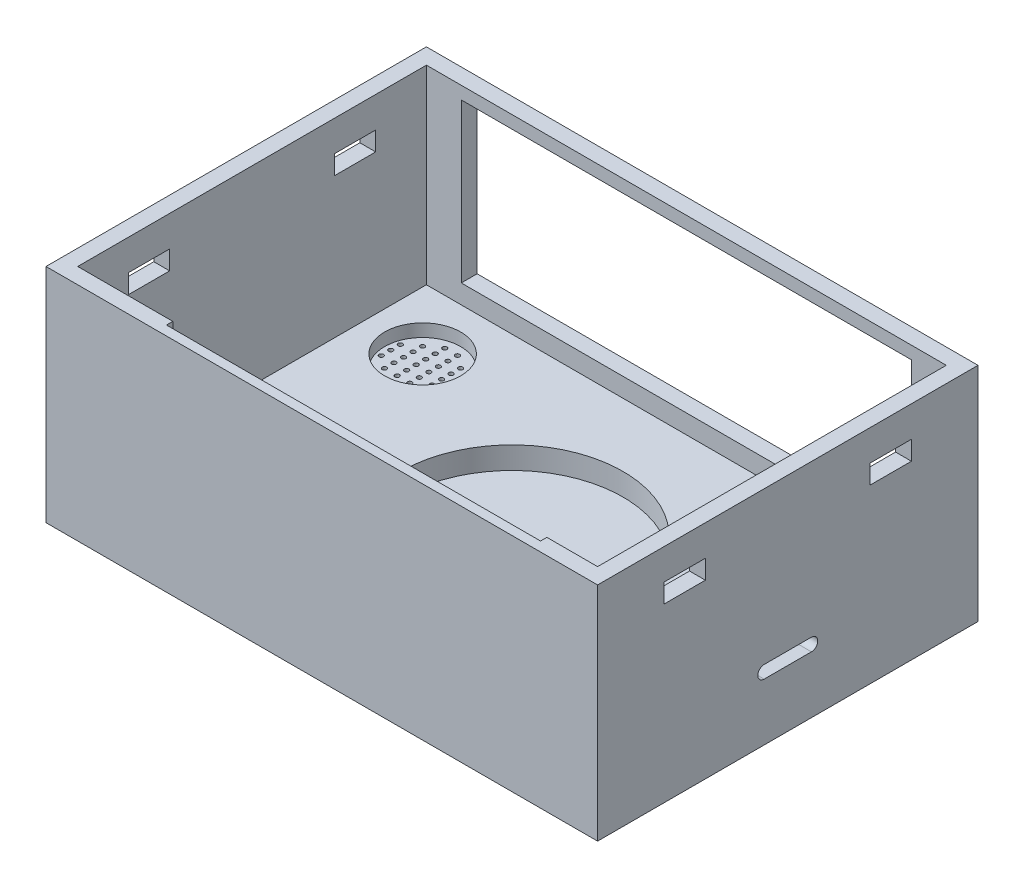
from build123d import *

# Parameters (mm, degrees)
SKETCH1_W               = 87
SKETCH1_H               = 60
HOUSING_DEPTH           = 35
SKETCH4_W               = 82
SKETCH4_H               = 55
HOUSEINTERNALCUT_DEPTH  = 30
SKETCH6_W               = 3.7
SKETCH6_H               = 8.5
SWITCHEXTERNALCUT_DEPTH = 2
SKETCH8_W               = 1.7
SKETCH8_H               = 3.6
SWITCHINTERNALCUT_DEPTH = 4
SKETCH10_R              = 6
BUZZEREXTERNALCUT_DEPTH = 2
SKETCH12_R              = 0.35
BUZZERINTERNALCUT_DEPTH = 4
SKETCH14_W              = 4.6
SKETCH14_H              = 6.1
BUTTONEXTERNALCUT_DEPTH = 2
SKETCH16_R              = 1.5
BUTTONINTERNALCUT_DEPTH = 4
SKETCH29_R              = 17.515
WICHARGECUT_DEPTH       = 3.5
SKETCH30_W              = 59
SKETCH30_H              = 39
RFIDMODULECUT_DEPTH     = 1
SKETCH32_W              = 71
SKETCH32_H              = 25
DISPLAYCUT_DEPTH        = 3.5
MICROUSBCUT_DEPTH       = 2.5
SKETCH34_W              = 6.5
SKETCH34_H              = 3
CLIPSCUT_DEPTH          = 88
SKETCH35_R              = 0.45
RESETCUT_DEPTH          = 6


with BuildPart() as part:
    # Sketch1 → Housing (new body)
    with BuildSketch(Plane(origin=(0, 0, 0), x_dir=(1, 0, 0), z_dir=(0, 1, 0))):
        with Locations((6.529661017, 6.430084746)):
            Rectangle(SKETCH1_W, SKETCH1_H)
    extrude(amount=HOUSING_DEPTH)

    # Sketch4 → HouseInternalCut (cut)
    with BuildSketch(Plane(origin=(0, 35, 0), x_dir=(1, 0, 0), z_dir=(0, 1, 0))):
        with Locations((6.529661017, 6.430084746)):
            Rectangle(SKETCH4_W, SKETCH4_H)
    extrude(amount=-HOUSEINTERNALCUT_DEPTH, mode=Mode.SUBTRACT)

    # Sketch6 → SwitchExternalCut (cut)
    with BuildSketch(Plane(origin=(-29.459679841, 5, 17.678662656), x_dir=(1, 0, 0), z_dir=(0, 1, 0))):
        with Locations((4.354897879, 7.989454328)):
            Rectangle(SKETCH6_W, SKETCH6_H)
    extrude(amount=-SWITCHEXTERNALCUT_DEPTH, mode=Mode.SUBTRACT)

    # Sketch8 → SwitchInternalCut (cut, through all)
    with BuildSketch(Plane(origin=(-29.459679841, 3, 17.678662656), x_dir=(1, 0, 0), z_dir=(0, 1, 0))):
        with Locations((4.354897879, 7.989454328)):
            Rectangle(SKETCH8_W, SKETCH8_H)
    extrude(amount=-SWITCHINTERNALCUT_DEPTH, mode=Mode.SUBTRACT)

    # Sketch10 → BuzzerExternalCut (cut)
    with BuildSketch(Plane(origin=(-0.314920006, 5, -24.188639302), x_dir=(1, 0, 0), z_dir=(0, 1, 0))):
        with Locations((-25.006618322, 0)):
            Circle(SKETCH10_R)
    extrude(amount=-BUZZEREXTERNALCUT_DEPTH, mode=Mode.SUBTRACT)

    # Sketch12 → BuzzerInternalCut (cut, through all)
    with BuildSketch(Plane(origin=(-0.314920006, 3, -24.188639302), x_dir=(1, 0, 0), z_dir=(0, 1, 0))):
        with Locations((-24.042348329, 4.522315504)):
            Circle(SKETCH12_R)
        with Locations((-26.042348329, 3.020429056)):
            Circle(SKETCH12_R)
        with Locations((-28.042348329, 3.020429056)):
            Circle(SKETCH12_R)
        with Locations((-30.042348329, 1.518542609)):
            Circle(SKETCH12_R)
        with Locations((-30.042348329, 0.016656161)):
            Circle(SKETCH12_R)
        with Locations((-30.042348329, -1.485230286)):
            Circle(SKETCH12_R)
        with Locations((-28.042348329, 0.016656161)):
            Circle(SKETCH12_R)
        with Locations((-28.042348329, 1.518542609)):
            Circle(SKETCH12_R)
        with Locations((-28.042348329, -1.485230286)):
            Circle(SKETCH12_R)
        with Locations((-28.042348329, -2.987116733)):
            Circle(SKETCH12_R)
        with Locations((-26.042348329, 0.016656161)):
            Circle(SKETCH12_R)
        with Locations((-26.042348329, 1.518542609)):
            Circle(SKETCH12_R)
        with Locations((-26.042348329, -1.485230286)):
            Circle(SKETCH12_R)
        with Locations((-26.042348329, -2.987116733)):
            Circle(SKETCH12_R)
        with Locations((-26.042348329, -4.489003181)):
            Circle(SKETCH12_R)
        with Locations((-24.042348329, -4.489003181)):
            Circle(SKETCH12_R)
        with Locations((-24.042348329, -2.987116733)):
            Circle(SKETCH12_R)
        with Locations((-24.042348329, -1.485230286)):
            Circle(SKETCH12_R)
        with Locations((-24.042348329, 0.016656161)):
            Circle(SKETCH12_R)
        with Locations((-24.042348329, 1.518542609)):
            Circle(SKETCH12_R)
        with Locations((-24.042348329, 3.020429056)):
            Circle(SKETCH12_R)
        with Locations((-22.042348329, 3.020429056)):
            Circle(SKETCH12_R)
        with Locations((-22.042348329, 1.518542609)):
            Circle(SKETCH12_R)
        with Locations((-22.042348329, 0.016656161)):
            Circle(SKETCH12_R)
        with Locations((-22.042348329, -1.485230286)):
            Circle(SKETCH12_R)
        with Locations((-22.042348329, -2.987116733)):
            Circle(SKETCH12_R)
        with Locations((-20.042348329, -1.485230286)):
            Circle(SKETCH12_R)
        with Locations((-20.042348329, 0.016656161)):
            Circle(SKETCH12_R)
        with Locations((-20.042348329, 1.518542609)):
            Circle(SKETCH12_R)
        with Locations((-26.042348329, 4.522315504)):
            Circle(SKETCH12_R)
    extrude(amount=-BUZZERINTERNALCUT_DEPTH, mode=Mode.SUBTRACT)

    # Sketch14 → ButtonExternalCut (cut)
    with BuildSketch(Plane(origin=(-24.227687265, 5, -14.72402786), x_dir=(1, 0, 0), z_dir=(0, 1, 0))):
        with Locations((-1.096336387, -10.602688636)):
            Rectangle(SKETCH14_W, SKETCH14_H)
    extrude(amount=-BUTTONEXTERNALCUT_DEPTH, mode=Mode.SUBTRACT)

    # Sketch16 → ButtonInternalCut (cut, through all)
    with BuildSketch(Plane(origin=(-24.227687265, 3, -14.72402786), x_dir=(1, 0, 0), z_dir=(0, 1, 0))):
        with Locations((-1.096336387, -10.602688636)):
            Circle(SKETCH16_R)
    extrude(amount=-BUTTONINTERNALCUT_DEPTH, mode=Mode.SUBTRACT)

    # Sketch29 → WiChargeCut (cut)
    with BuildSketch(Plane(origin=(0, 5, 0), x_dir=(1, 0, 0), z_dir=(0, 1, 0))):
        with Locations((6.529661017, 6.430084746)):
            Circle(SKETCH29_R)
    extrude(amount=-WICHARGECUT_DEPTH, mode=Mode.SUBTRACT)

    # Sketch30 → RFIDModuleCut (cut)
    with BuildSketch(Plane(origin=(0, 0, 21.069915254), x_dir=(-1, 0, 0), z_dir=(0, 0, -1))):
        with Locations((-10.029661017, 25.5)):
            Rectangle(SKETCH30_W, SKETCH30_H)
    extrude(amount=-RFIDMODULECUT_DEPTH, mode=Mode.SUBTRACT)

    # Sketch32 → DisplayCut (cut, through all)
    with BuildSketch(Plane.XY.offset(-33.930084746)):
        with Locations((6.529661017, 20.5)):
            Rectangle(SKETCH32_W, SKETCH32_H)
    extrude(amount=-DISPLAYCUT_DEPTH, mode=Mode.SUBTRACT)

    # Sketch33 → MicroUSBCut (cut)
    with BuildSketch(Plane(origin=(50.029661017, 0, 0), x_dir=(0, 0, -1), z_dir=(1, 0, 0))):
        with BuildLine():
            Line((2.705084746, 11), (10.155084746, 11))
            ThreePointArc((10.155084746, 11), (11.155084746, 10), (10.155084746, 9))
            Line((10.155084746, 9), (2.705084746, 9))
            ThreePointArc((2.705084746, 9), (1.705084746, 10), (2.705084746, 11))
        make_face()
    extrude(amount=-MICROUSBCUT_DEPTH, mode=Mode.SUBTRACT)

    # Sketch34 → ClipsCut (cut, through all)
    with BuildSketch(Plane.ZY.offset(36.970338983)):
        with Locations((-22.680084746, 28.64745115)):
            Rectangle(SKETCH34_W, SKETCH34_H)
        with Locations((9.819915254, 28.64745115)):
            Rectangle(SKETCH34_W, SKETCH34_H)
    extrude(amount=-CLIPSCUT_DEPTH, mode=Mode.SUBTRACT)

    # Sketch35 → ResetCut (cut, through all)
    with BuildSketch(Plane(origin=(0, 5, 0), x_dir=(1, 0, 0), z_dir=(0, 1, 0))):
        with Locations((46.529661017, -2.509915254)):
            Circle(SKETCH35_R)
    extrude(amount=-RESETCUT_DEPTH, mode=Mode.SUBTRACT)


solid = part.part
